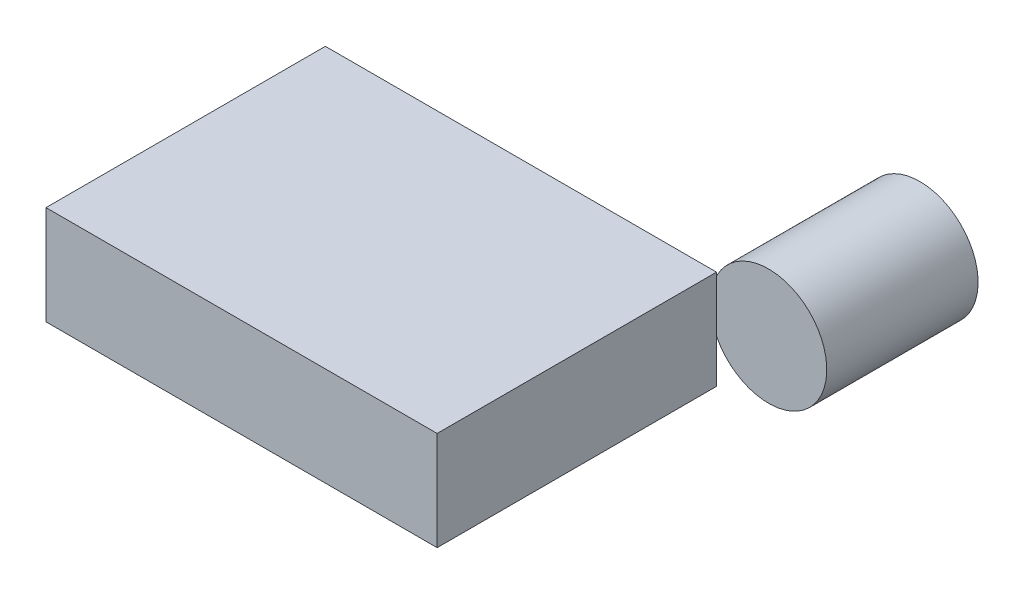
from build123d import *

# Parameters (mm, degrees)
SKETCH1_W           = 33.6
SKETCH1_H           = 24
BOSS_EXTRUDE1_DEPTH = 8.5
SKETCH2_R           = 5
BOSS_EXTRUDE2_DEPTH = 13


with BuildPart() as part:
    # Sketch1 → Boss-Extrude1 (new body)
    with BuildSketch(Plane(origin=(0, 0, 0), x_dir=(1, 0, 0), z_dir=(0, 1, 0))):
        Rectangle(SKETCH1_W, SKETCH1_H)
    extrude(amount=BOSS_EXTRUDE1_DEPTH)


with BuildPart() as body_2:
    # Sketch2 → Boss-Extrude2 (new body)
    with BuildSketch(Plane(origin=(0, 0, -12), x_dir=(-1, 0, 0), z_dir=(0, 0, -1))):
        with Locations((-21.271091385, 5.975266173)):
            Circle(SKETCH2_R)
    extrude(amount=BOSS_EXTRUDE2_DEPTH)


solid = Compound([part.part, body_2.part])
